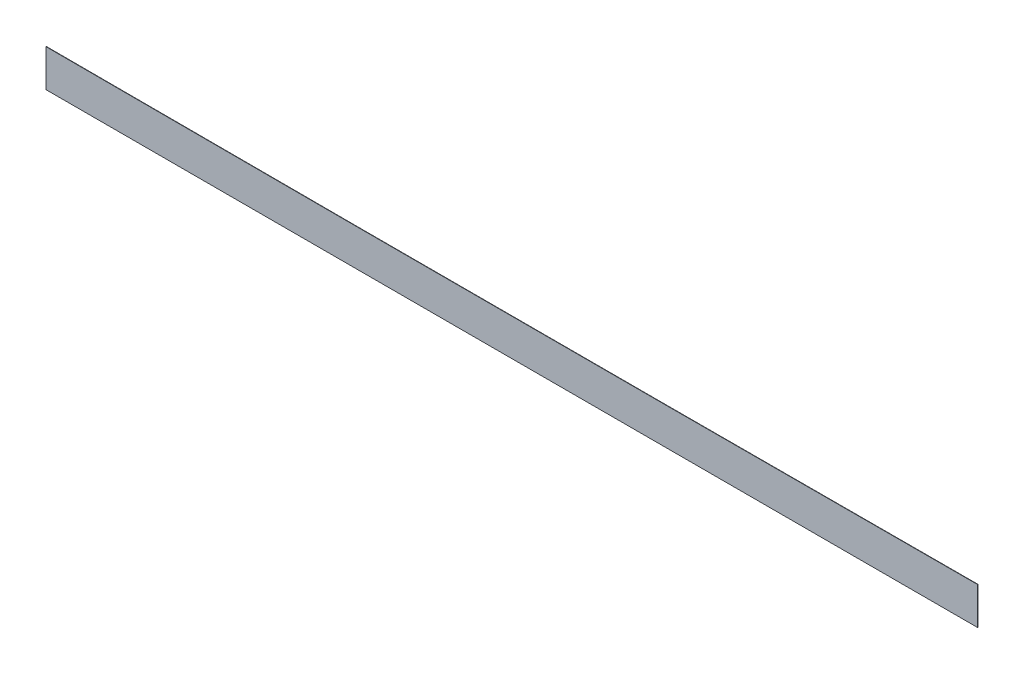
from build123d import *

# Parameters (mm, degrees)
AUFSATZ_LINEAR_AUSTRAGEN1_DEPTH = 1


with BuildPart() as part:
    # Skizze1 → Aufsatz-Linear austragen1 (new body)
    with BuildSketch(Plane.XY):
        with BuildLine():
            Line((-1250, 100), (-1250, 0))
            Line((-1250, 0), (1250, 0))
            Line((1250, 0), (1250, 100))
            ThreePointArc((1250, 100), (0, 98.5), (-1250, 100))
        make_face()
    extrude(amount=AUFSATZ_LINEAR_AUSTRAGEN1_DEPTH)


solid = part.part
